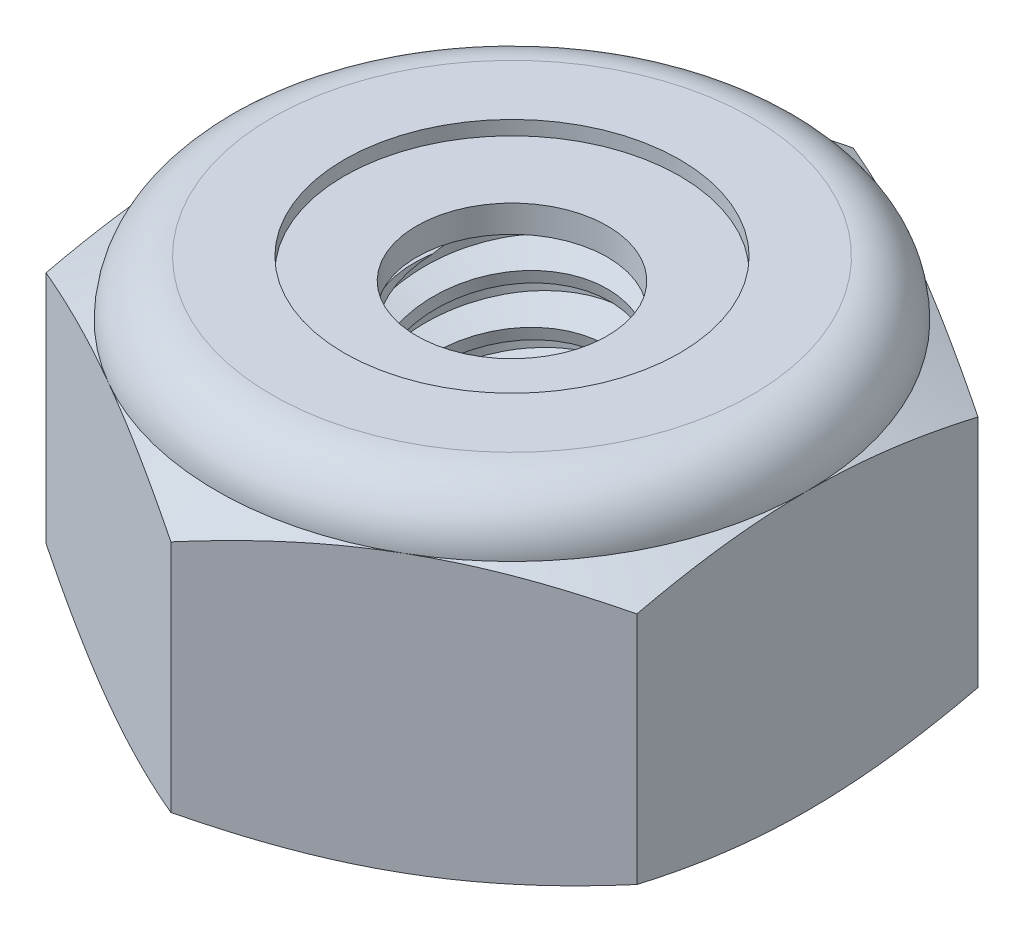
from build123d import *

# Parameters (mm, degrees)
EXTRUDE1_DEPTH      = 3.571875
SKETCH2_W           = 1.2573
SKETCH2_H           = 3.571875
LPATTERN1_COUNT     = 7
LPATTERN1_PITCH     = 0.529166667
LPATTERN1_COL_COUNT = 2
LPATTERN1_COL_PITCH = 0.529166667


with BuildPart() as part:
    # Sketch1 → Extrude1 (new body)
    with BuildSketch(Plane(origin=(0, 0, 0), x_dir=(1, 0, 0), z_dir=(0, 1, 0))):
        Polygon((0, 3.666174209), (-3.175, 1.833087105), (-3.175, -1.833087105), (0, -3.666174209), (3.175, -1.833087105), (3.175, 1.833087105), align=None)
    extrude(amount=EXTRUDE1_DEPTH)

    # Sketch4 → Cut-Revolve2 (revolve, cut)
    with BuildSketch(Plane(origin=(0, 0, 0), x_dir=(0, 0, -1), z_dir=(1, 0, 0))):
        Polygon((0, 3.571875), (1.2573, 3.571875), (1.024693253, 3.463408692), (1.024693253, 0.108466308), (1.2573, 0), (0, 0), align=None)
    revolve(axis=Axis((0, 3.571875, 0), (0, 1, 0)), mode=Mode.SUBTRACT)


with BuildPart() as body_2:
    # Sketch2 → Revolve1 (revolve)
    with BuildSketch(Plane(origin=(0, 0, 0), x_dir=(0, 0, -1), z_dir=(1, 0, 0))):
        with Locations((0.62865, 1.7859375)):
            Rectangle(SKETCH2_W, SKETCH2_H)
    revolve(axis=Axis((0, -1.2573, 0), (0, 1, 0)))

    # Sketch3 → Cut-Revolve1 (revolve, cut)
    with BuildSketch(Plane(origin=(0, 0, 0), x_dir=(0, 0, -1), z_dir=(1, 0, 0))):
        Polygon((1.270921243, 3.507146853), (1.366269944, 3.054049825), (1.051935739, 3.156888479), (1.024693253, 3.286344773), align=None)
    cut_revolve1 = revolve(axis=Axis((0, 3.571875, 0.11968832), (0, -0.978567261, -0.205927454)), mode=Mode.SUBTRACT)

    # LPattern1: Cut-Revolve1 ×7
    with Locations(*[(0, -i * LPATTERN1_PITCH, 0) for i in range(1, LPATTERN1_COUNT)]):
        add(cut_revolve1, mode=Mode.SUBTRACT)

    # LPattern1 col: Cut-Revolve1 ×2
    with Locations(*[(0, i * LPATTERN1_COL_PITCH, 0) for i in range(1, LPATTERN1_COL_COUNT)]):
        add(cut_revolve1, mode=Mode.SUBTRACT)


with BuildPart() as part_1:
    add(part.part)

    # Combine1: cut body 2
    add(body_2.part, mode=Mode.SUBTRACT)

    # Sketch5 → Cut-Revolve3 (revolve, cut)
    with BuildSketch(Plane(origin=(0, 0, 0), x_dir=(0, 0, -1), z_dir=(1, 0, 0))):
        with BuildLine():
            Line((0, 0), (3.175, 0))
            Line((3.175, 0), (3.666174209, 0.229038295))
            Line((3.666174209, 0.229038295), (3.666174209, 2.747524205))
            Line((3.666174209, 2.747524205), (3.175, 2.9765625))
            ThreePointArc((3.175, 2.9765625), (3.000637006, 3.397512006), (2.5796875, 3.571875))
            Line((2.5796875, 3.571875), (2.5796875, 4.841875))
            Line((2.5796875, 4.841875), (4.936174209, 4.841875))
            Line((4.936174209, 4.841875), (4.936174209, -1.27))
            Line((4.936174209, -1.27), (0, -1.27))
            Line((0, -1.27), (0, 0))
        make_face()
    revolve(axis=Axis((0, 0, 0), (0, 1, 0)), mode=Mode.SUBTRACT)

    # Sketch6 → Cut-Revolve4 (revolve, cut)
    with BuildSketch(Plane(origin=(0, 0, 0), x_dir=(0, 0, -1), z_dir=(1, 0, 0))):
        with BuildLine():
            Line((0, 2.9765625), (3.0226, 2.9765625))
            ThreePointArc((3.0226, 2.9765625), (2.892873932, 3.289748932), (2.5796875, 3.419475))
            Line((2.5796875, 3.419475), (1.802190376, 3.419475))
            Line((1.802190376, 3.419475), (1.802190376, 4.841875))
            Line((1.802190376, 4.841875), (0, 4.841875))
            Line((0, 4.841875), (0, 2.9765625))
        make_face()
    revolve(axis=Axis((0, 4.841875, 0), (0, 1, 0)), mode=Mode.SUBTRACT)


with BuildPart() as body_2_2:
    # Sketch7 → Revolve2 (revolve)
    with BuildSketch(Plane(origin=(0, 0, 0), x_dir=(0, 0, -1), z_dir=(1, 0, 0))):
        with BuildLine():
            Line((1.024693253, 3.0527625), (2.938395763, 3.0527625))
            ThreePointArc((2.938395763, 3.0527625), (2.810484559, 3.261537543), (2.5796875, 3.343275))
            Line((2.5796875, 3.343275), (1.024693253, 3.343275))
            Line((1.024693253, 3.343275), (1.024693253, 3.0527625))
        make_face()
    revolve(axis=Axis((0, 3.0527625, 0), (0, 1, 0)))


solid = Compound([part_1.part, body_2_2.part])
